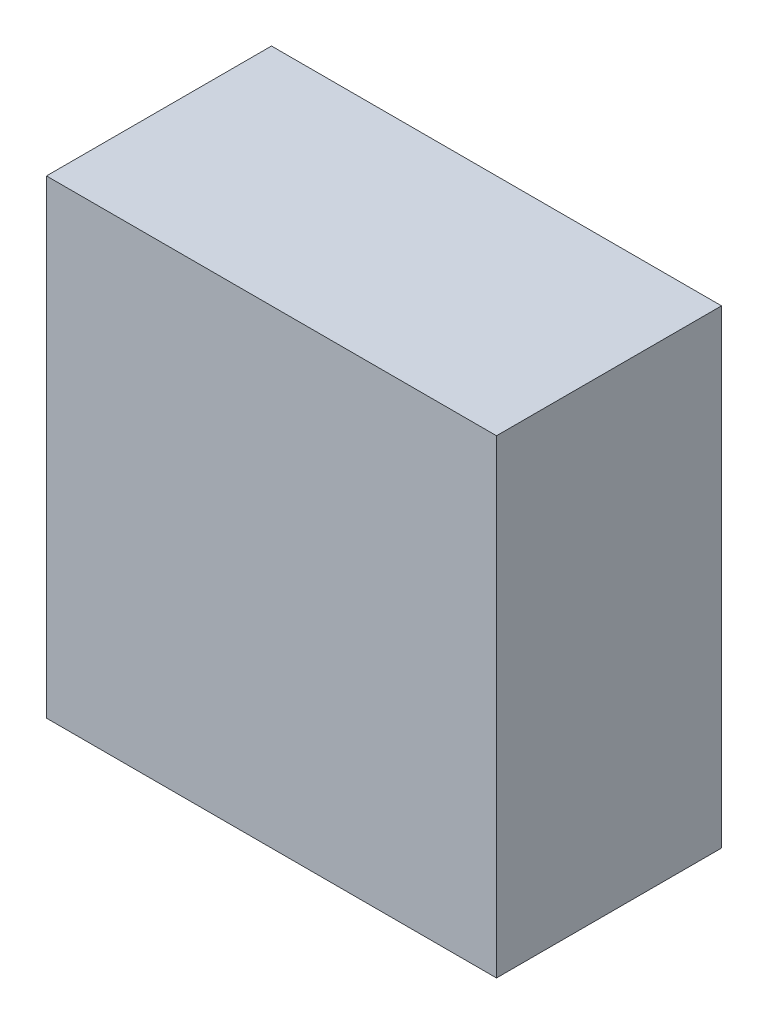
from build123d import *

# Parameters (mm, degrees)
SKETCH1_W           = 23
SKETCH1_H           = 11.5
BOSS_EXTRUDE1_DEPTH = 24


with BuildPart() as part:
    # Sketch1 → Boss-Extrude1 (new body)
    with BuildSketch(Plane(origin=(0, 0, 0), x_dir=(1, 0, 0), z_dir=(0, 1, 0))):
        with Locations((11.5, 5.75)):
            Rectangle(SKETCH1_W, SKETCH1_H)
    extrude(amount=BOSS_EXTRUDE1_DEPTH)


solid = part.part
